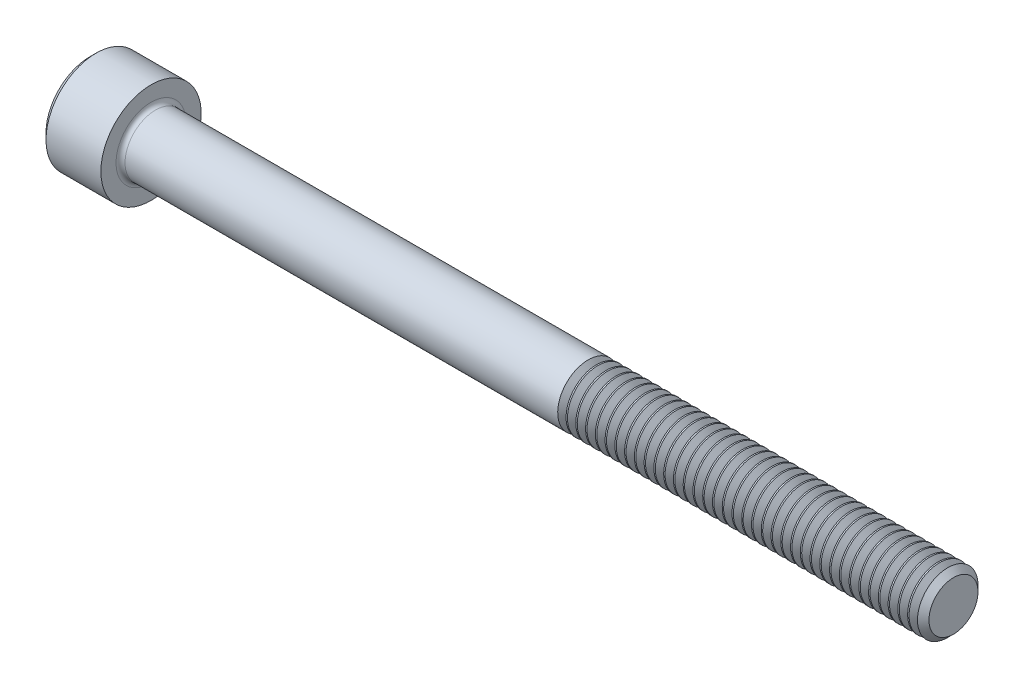
from build123d import *

# Parameters (mm, degrees)
FILLET1_R       = 0.3556
HEX_2_DEPTH     = 2.286
THDSCHPAT_COUNT = 37
THDSCHPAT_PITCH = 0.772297297


with BuildPart() as part:
    # BodySke → Base-Revolve (revolve)
    with BuildSketch(Plane.XY):
        Polygon((0, 0), (0, 3.48615), (0.4826, 3.96875), (4.826, 3.96875), (4.826, 2.413), (67.85356, 2.413), (68.326, 1.94056), (68.326, 0), align=None)
    revolve(axis=Axis((-31.75, 0, 0), (1, 0, 0)))

    # Fillet1
    fillet1_edges = [part.edges().sort_by_distance(p)[0] for p in [
        (4.826, -2.413, 0),
    ]]
    fillet(fillet1_edges, radius=FILLET1_R)

    # Sketch2 → Hex-PreBroach (revolve, cut)
    with BuildSketch(Plane.XY):
        Polygon((0, 1.98501), (2.286, 1.98501), (3.432046058, 0), (0, 0), align=None)
    revolve(axis=Axis((0, 0, 0), (1, 0, 0)), mode=Mode.SUBTRACT)

    # Sketch3 → Hex 2 (cut)
    with BuildSketch(Plane(origin=(0, 0, 0), x_dir=(0, 0.5, 0.866025404), z_dir=(-1, 0, 0))):
        Polygon((1.146046058, 1.98501), (-1.146046058, 1.98501), (-2.292092116, 0), (-1.146046058, -1.98501), (1.146046058, -1.98501), (2.292092116, 0), align=None)
    extrude(amount=-HEX_2_DEPTH, mode=Mode.SUBTRACT)

    # ThdSchSke → ThreadSchematic (revolve, cut)
    with BuildSketch(Plane.XY):
        Polygon((39.751, -1.94056), (39.420193951, -2.413), (39.420193951, -3.01625), (40.081806049, -3.01625), (40.081806049, -2.413), align=None)
    threadschematic = revolve(axis=Axis((-3.175, 0, 0), (1, 0, 0)), mode=Mode.SUBTRACT)

    # ThdSchPat: ThreadSchematic ×37
    with Locations(*[(i * THDSCHPAT_PITCH, 0, 0) for i in range(1, THDSCHPAT_COUNT)]):
        add(threadschematic, mode=Mode.SUBTRACT)


solid = part.part
